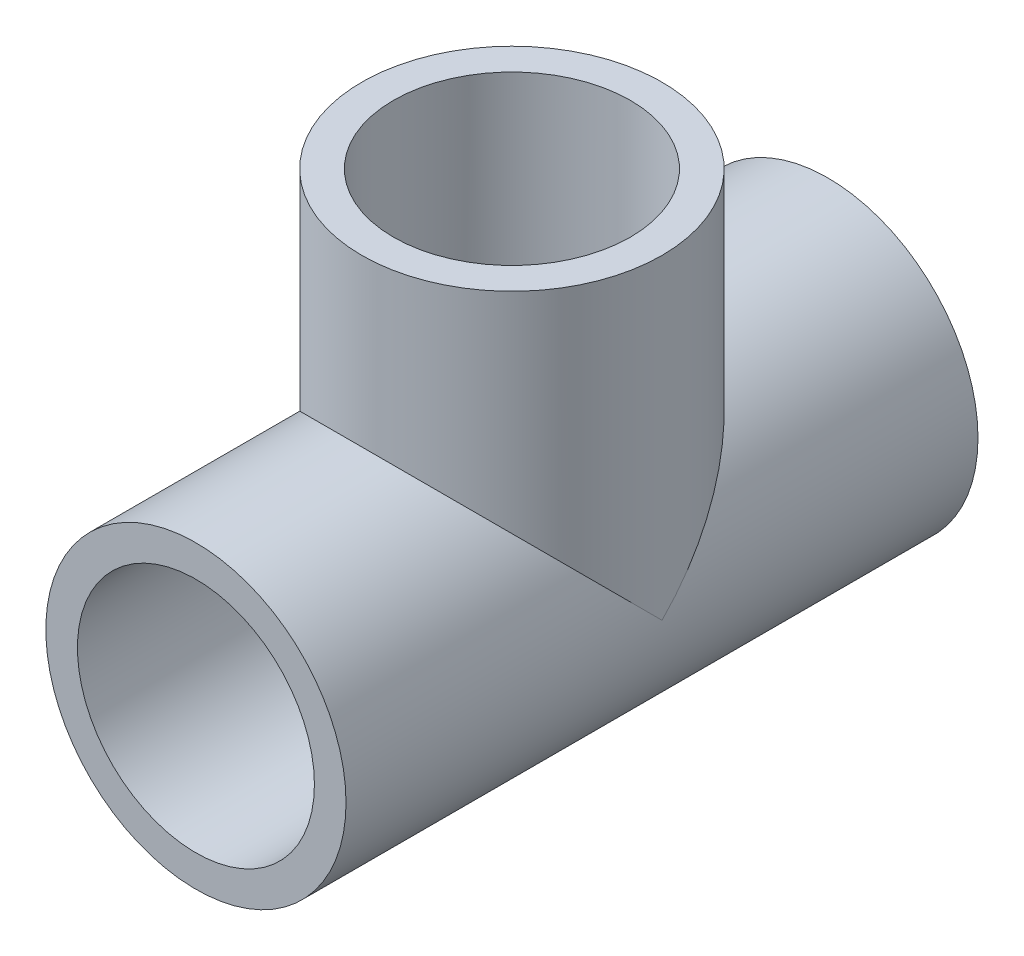
from build123d import *

# Parameters (mm, degrees)
SKETCH1_R           = 24.13
SKETCH1_R_2         = 19.05
BOSS_EXTRUDE1_DEPTH = 101.6
SKETCH2_R           = 24.13
SKETCH2_R_2         = 19.05
BOSS_EXTRUDE2_DEPTH = 50.8
SKETCH3_R           = 19.05
CUT_EXTRUDE1_DEPTH  = 102.6000001


with BuildPart() as part:
    # Sketch1 → Boss-Extrude1 (new body)
    with BuildSketch(Plane.XY):
        Circle(SKETCH1_R)
        Circle(SKETCH1_R_2, mode=Mode.SUBTRACT)
    extrude(amount=BOSS_EXTRUDE1_DEPTH)

    # Sketch2 → Boss-Extrude2 (add)
    with BuildSketch(Plane(origin=(0, 0, 0), x_dir=(1, 0, 0), z_dir=(0, 1, 0))):
        with Locations((0, -50.8)):
            Circle(SKETCH2_R)
        with Locations((0, -50.8)):
            Circle(SKETCH2_R_2, mode=Mode.SUBTRACT)
    extrude(amount=BOSS_EXTRUDE2_DEPTH)

    # Sketch3 → Cut-Extrude1 (cut, through all)
    with BuildSketch(Plane.XY.offset(101.6)):
        Circle(SKETCH3_R)
    extrude(amount=-CUT_EXTRUDE1_DEPTH, mode=Mode.SUBTRACT)


solid = part.part
